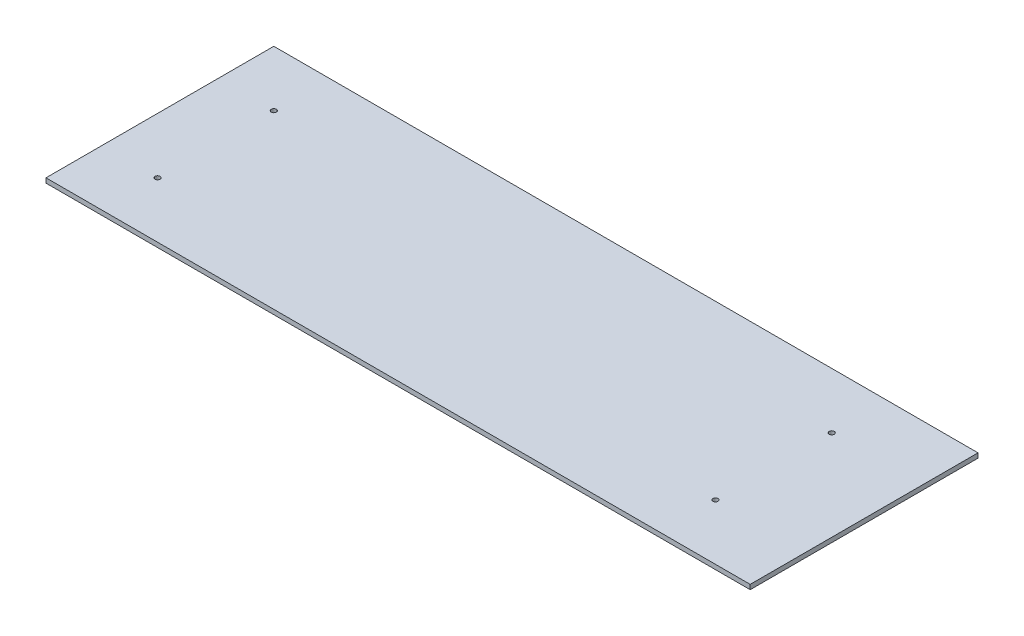
from build123d import *

# Parameters (mm, degrees)
SKETCH1_W                    = 961.792682927
SKETCH1_H                    = 311.15
BOSS_EXTRUDE1_DEPTH          = 6.35
TAP_DRILL_FOR_5_16_24_TAP1_D = 6.9088
TAP_DRILL_FOR_5_16_24_TAP2_D = 6.9088
TAP_DRILL_FOR_5_16_24_TAP3_D = 6.9088
TAP_DRILL_FOR_5_16_24_TAP4_D = 6.9088


with BuildPart() as part:
    # Sketch1 → Boss-Extrude1 (new body)
    with BuildSketch(Plane(origin=(0, 0, 0), x_dir=(1, 0, 0), z_dir=(0, 1, 0))):
        with Locations((480.896341464, 155.575)):
            Rectangle(SKETCH1_W, SKETCH1_H)
    extrude(amount=BOSS_EXTRUDE1_DEPTH)

    # Tap Drill for 5/16-24 Tap1 (through all)
    with Locations(Plane(origin=(0, 6.35, 0), x_dir=(1, 0, 0), z_dir=(0, 1, 0))):
        with Locations((76.2, 76.2)):
            Hole(TAP_DRILL_FOR_5_16_24_TAP1_D / 2)

    # Tap Drill for 5/16-24 Tap2 (through all)
    with Locations(Plane(origin=(0, 6.35, 0), x_dir=(1, 0, 0), z_dir=(0, 1, 0))):
        with Locations((76.2, 234.95)):
            Hole(TAP_DRILL_FOR_5_16_24_TAP2_D / 2)

    # Tap Drill for 5/16-24 Tap3 (through all)
    with Locations(Plane(origin=(0, 6.35, 0), x_dir=(1, 0, 0), z_dir=(0, 1, 0))):
        with Locations((838.2, 76.2)):
            Hole(TAP_DRILL_FOR_5_16_24_TAP3_D / 2)

    # Tap Drill for 5/16-24 Tap4 (through all)
    with Locations(Plane(origin=(0, 6.35, 0), x_dir=(1, 0, 0), z_dir=(0, 1, 0))):
        with Locations((838.2, 234.95)):
            Hole(TAP_DRILL_FOR_5_16_24_TAP4_D / 2)


solid = part.part
